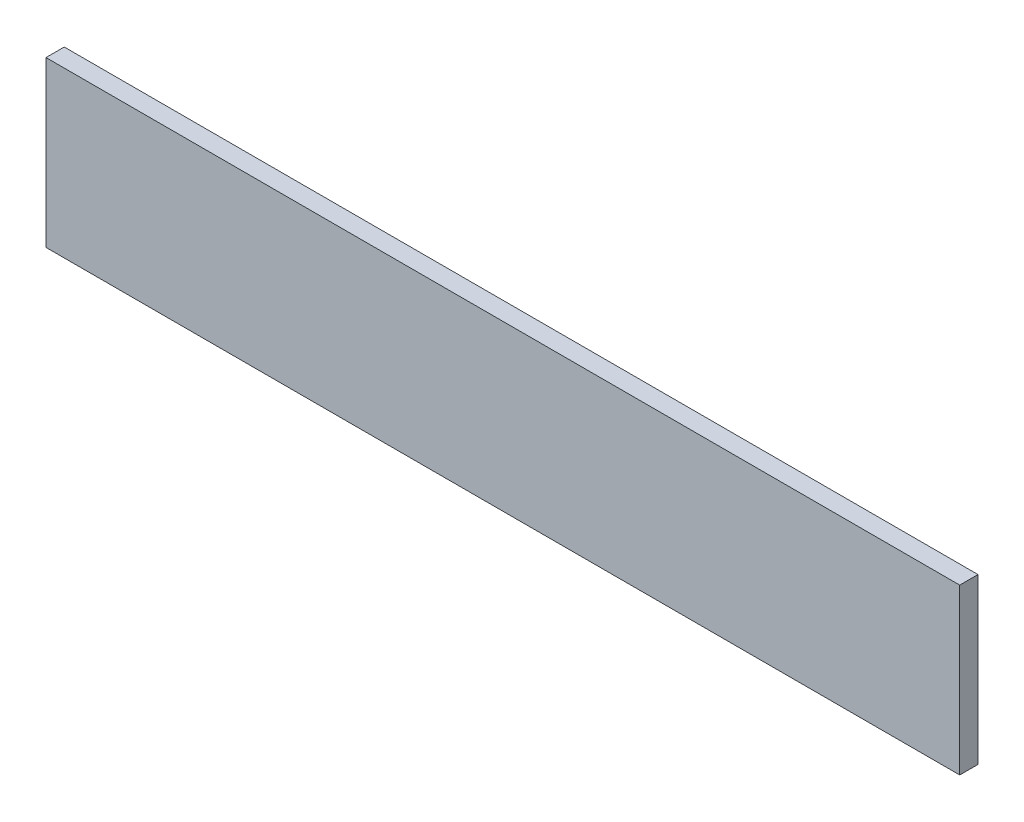
from build123d import *

# Parameters (mm, degrees)
SKETCH1_W           = 635
SKETCH1_H           = 114.3
BOSS_EXTRUDE1_DEPTH = 12.7


with BuildPart() as part:
    # Sketch1 → Boss-Extrude1 (new body)
    with BuildSketch(Plane.XY):
        Rectangle(SKETCH1_W, SKETCH1_H)
    extrude(amount=BOSS_EXTRUDE1_DEPTH)


solid = part.part
